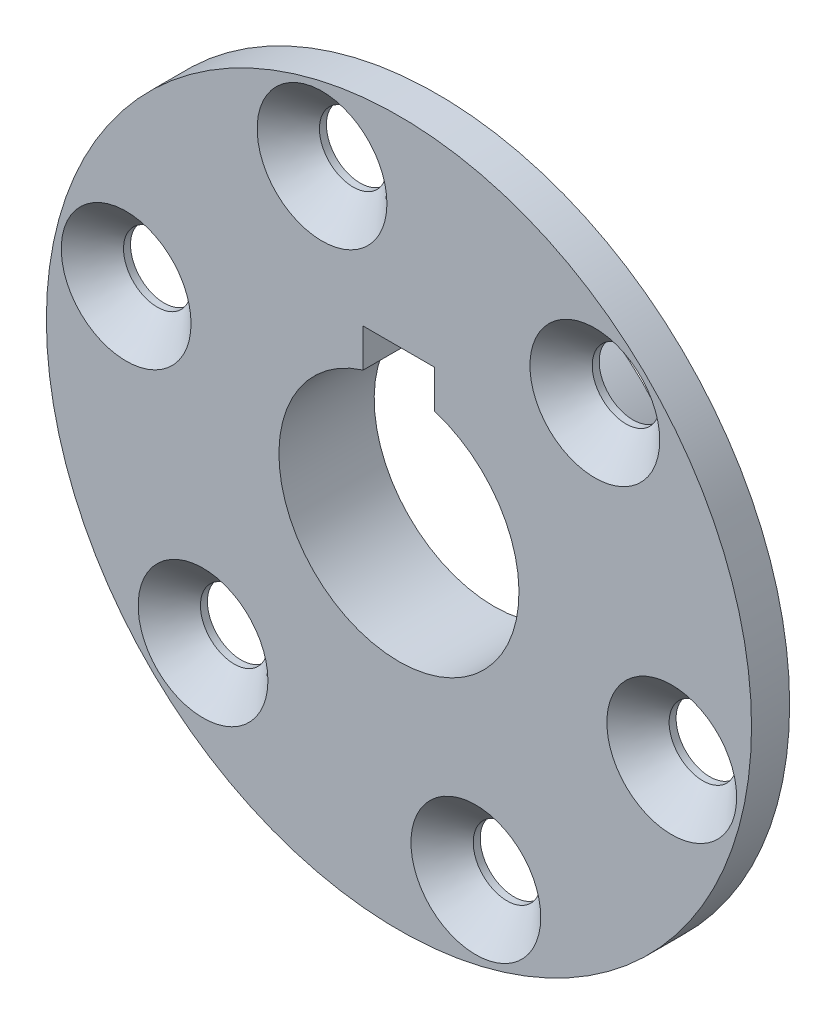
from build123d import *

# Parameters (mm, degrees)
SKETCH1_R                                      = 47
BOSS_EXTRUDE1_DEPTH                            = 5.08
CSK_FOR_M8_FLAT_HEAD_MACHINE_SCREW1_AT_2_COUNT = 2
CSK_FOR_M8_FLAT_HEAD_MACHINE_SCREW1_AT_2_PITCH = 37.5
CSK_FOR_M8_FLAT_HEAD_MACHINE_SCREW1_AT_3_COUNT = 2
CSK_FOR_M8_FLAT_HEAD_MACHINE_SCREW1_AT_3_PITCH = 37.5
CSK_FOR_M8_FLAT_HEAD_MACHINE_SCREW1_AT_4_COUNT = 2
CSK_FOR_M8_FLAT_HEAD_MACHINE_SCREW1_AT_4_PITCH = 64.951905284
CSK_FOR_M8_FLAT_HEAD_MACHINE_SCREW1_AT_5_COUNT = 2
CSK_FOR_M8_FLAT_HEAD_MACHINE_SCREW1_AT_5_PITCH = 75
CSK_FOR_M8_FLAT_HEAD_MACHINE_SCREW1_AT_6_COUNT = 2
CSK_FOR_M8_FLAT_HEAD_MACHINE_SCREW1_AT_6_PITCH = 64.951905284
SKETCH11_R                                     = 27.94
BOSS_EXTRUDE2_DEPTH                            = 7.62


with BuildPart() as part:
    # Sketch1 → Boss-Extrude1 (new body)
    with BuildSketch(Plane.XY):
        Circle(SKETCH1_R)
        with BuildLine():
            Line((-4.7625, 20.354769843), (-4.7625, 15.274769843))
            ThreePointArc((-4.7625, 15.274769843), (0, -16), (4.7625, 15.274769843))
            Line((4.7625, 15.274769843), (4.7625, 20.354769843))
            Line((4.7625, 20.354769843), (-4.7625, 20.354769843))
        make_face(mode=Mode.SUBTRACT)
    extrude(amount=BOSS_EXTRUDE1_DEPTH)

    # Sketch10 → CSK for M8 Flat Head Machine Screw1 (revolve, cut)
    with BuildSketch(Plane(origin=(-10.251484687, 36.071554745, 5.08), x_dir=(0, -1, 0), z_dir=(1, 0, 0))):
        Polygon((0, 0), (0, 5.08), (4.5, 5.08), (4.5, 4.15), (8.65, 0), align=None)
    csk_for_m8_flat_head_machine_screw1 = revolve(axis=Axis((-10.251484687, 36.071554745, 11.43), (0, 0, -1)), mode=Mode.SUBTRACT)

    # CSK for M8 Flat Head Machine Screw1 at 2: CSK for M8 Flat Head Machine Screw1 ×2
    with Locations(*[Vector(0.969723336, -0.244206166, 0) * (i * CSK_FOR_M8_FLAT_HEAD_MACHINE_SCREW1_AT_2_PITCH) for i in range(1, CSK_FOR_M8_FLAT_HEAD_MACHINE_SCREW1_AT_2_COUNT)]):
        add(csk_for_m8_flat_head_machine_screw1, mode=Mode.SUBTRACT)

    # CSK for M8 Flat Head Machine Screw1 at 3: CSK for M8 Flat Head Machine Screw1 ×2
    with Locations(*[Vector(-0.696350411, -0.717701961, 0) * (i * CSK_FOR_M8_FLAT_HEAD_MACHINE_SCREW1_AT_3_PITCH) for i in range(1, CSK_FOR_M8_FLAT_HEAD_MACHINE_SCREW1_AT_3_COUNT)]):
        add(csk_for_m8_flat_head_machine_screw1, mode=Mode.SUBTRACT)

    # CSK for M8 Flat Head Machine Screw1 at 4: CSK for M8 Flat Head Machine Screw1 ×2
    with Locations(*[Vector(0.717701961, -0.696350411, 0) * (i * CSK_FOR_M8_FLAT_HEAD_MACHINE_SCREW1_AT_4_PITCH) for i in range(1, CSK_FOR_M8_FLAT_HEAD_MACHINE_SCREW1_AT_4_COUNT)]):
        add(csk_for_m8_flat_head_machine_screw1, mode=Mode.SUBTRACT)

    # CSK for M8 Flat Head Machine Screw1 at 5: CSK for M8 Flat Head Machine Screw1 ×2
    with Locations(*[Vector(0.273372925, -0.961908127, 0) * (i * CSK_FOR_M8_FLAT_HEAD_MACHINE_SCREW1_AT_5_PITCH) for i in range(1, CSK_FOR_M8_FLAT_HEAD_MACHINE_SCREW1_AT_5_COUNT)]):
        add(csk_for_m8_flat_head_machine_screw1, mode=Mode.SUBTRACT)

    # CSK for M8 Flat Head Machine Screw1 at 6: CSK for M8 Flat Head Machine Screw1 ×2
    with Locations(*[Vector(-0.244206166, -0.969723336, 0) * (i * CSK_FOR_M8_FLAT_HEAD_MACHINE_SCREW1_AT_6_PITCH) for i in range(1, CSK_FOR_M8_FLAT_HEAD_MACHINE_SCREW1_AT_6_COUNT)]):
        add(csk_for_m8_flat_head_machine_screw1, mode=Mode.SUBTRACT)

    # Sketch11 → Boss-Extrude2 (add)
    with BuildSketch(Plane(origin=(0, 0, 0), x_dir=(-1, 0, 0), z_dir=(0, 0, -1))):
        Circle(SKETCH11_R)
        with BuildLine():
            ThreePointArc((4.7625, 15.274769843), (0, -16), (-4.7625, 15.274769843))
            Line((-4.7625, 15.274769843), (-4.7625, 20.354769843))
            Line((-4.7625, 20.354769843), (4.7625, 20.354769843))
            Line((4.7625, 20.354769843), (4.7625, 15.274769843))
        make_face(mode=Mode.SUBTRACT)
    extrude(amount=BOSS_EXTRUDE2_DEPTH)


solid = part.part
